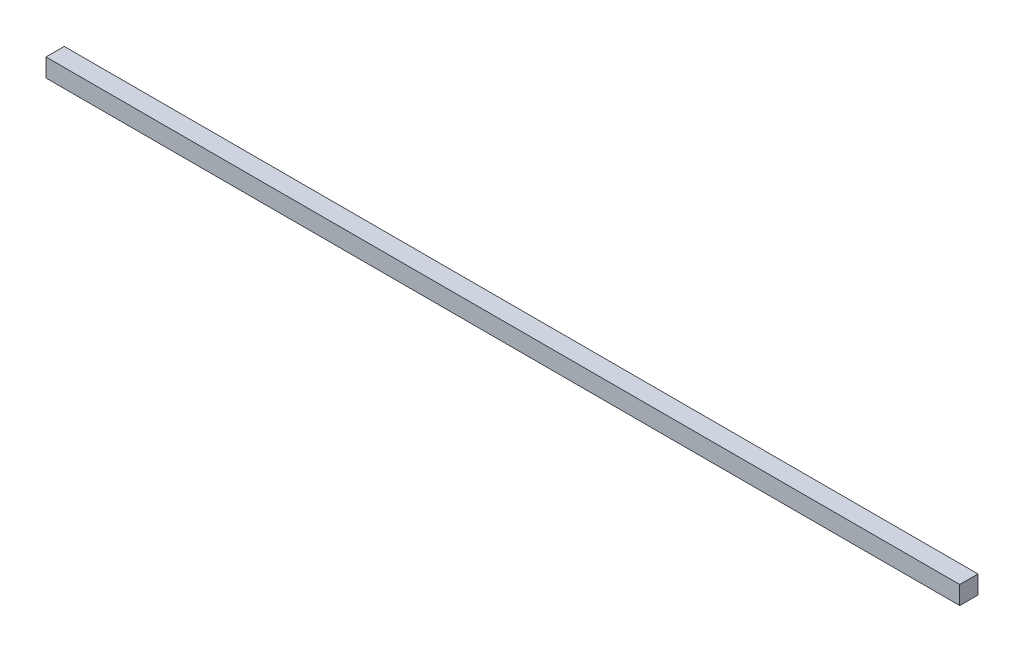
from build123d import *

# Parameters (mm, degrees)
SKETCH1_W           = 2
SKETCH1_H           = 2
BOSS_EXTRUDE1_DEPTH = 100


with BuildPart() as part:
    # Sketch1 → Boss-Extrude1 (new body)
    with BuildSketch(Plane(origin=(0, 0, 0), x_dir=(0, 0, -1), z_dir=(1, 0, 0))):
        Rectangle(SKETCH1_W, SKETCH1_H)
    extrude(amount=BOSS_EXTRUDE1_DEPTH)


solid = part.part
